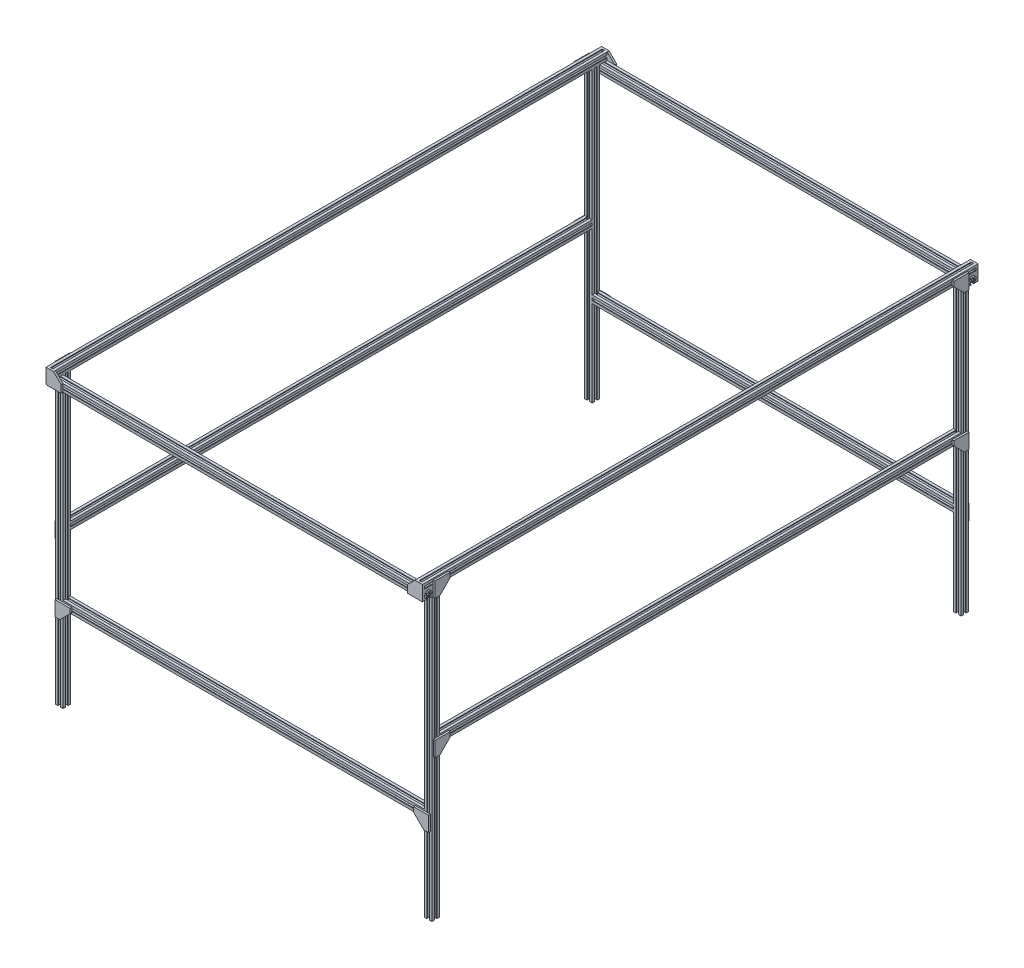
from build123d import *

# Parameters (mm, degrees)
SKETCH1_R                        = 2.5
VERTICAL_LEG_DEPTH               = 767.075
SKETCH2_R                        = 2.5
SHORT_HORIZONTAL_DEPTH           = 479.425
SKETCH3_R                        = 2.5
LONG_HORIZONTAL_DEPTH            = 692.15
SKETCH3_3_R                      = 2.5
LONG_HORIZONTAL_BACKWARDS_DEPTH  = 40
SKETCH2_3_R                      = 2.5
SHORT_HORIZONTAL_BACKWARDS_DEPTH = 20
BRACKETS_1_2_DEPTH               = 5
BRACKET_3_DEPTH                  = 5
BRACKET_4_DEPTH                  = 5


with BuildPart() as part:
    # Sketch1 → Vertical Leg (new body)
    with BuildSketch(Plane(origin=(0, 0, 0), x_dir=(1, 0, 0), z_dir=(0, 1, 0))):
        Polygon((-20, 6.8), (-20, 0), (-13.2, 0), (-13.2, 1.8), (-15.45, 1.8), (-15.45, 3.6), (-12.95, 6.1), (-7.05, 6.1), (-4.55, 3.6), (-4.55, 1.8), (-6.8, 1.8), (-6.8, 0), (0, 0), (0, 6.8), (-1.8, 6.8), (-1.8, 4.55), (-3.6, 4.55), (-6.1, 7.05), (-6.1, 12.95), (-3.6, 15.45), (-1.8, 15.45), (-1.8, 13.2), (0, 13.2), (0, 20), (-6.8, 20), (-6.8, 18.2), (-4.55, 18.2), (-4.55, 16.4), (-7.05, 13.9), (-12.95, 13.9), (-15.45, 16.4), (-15.45, 18.2), (-13.2, 18.2), (-13.2, 20), (-20, 20), (-20, 13.2), (-18.2, 13.2), (-18.2, 15.45), (-16.4, 15.45), (-13.9, 12.95), (-13.9, 7.05), (-16.4, 4.55), (-18.2, 4.55), (-18.2, 6.8), align=None)
        with Locations((-10, 10)):
            Circle(SKETCH1_R, mode=Mode.SUBTRACT)
    extrude(amount=VERTICAL_LEG_DEPTH)

    # Sketch2 → Short Horizontal (add)
    # profile 1 of 2: a face of its own
    with BuildSketch(Plane.ZY.offset(20)):
        Polygon((-20, 235.4), (-20, 228.6), (-13.2, 228.6), (-13.2, 230.4), (-15.45, 230.4), (-15.45, 232.2), (-12.95, 234.7), (-7.05, 234.7), (-4.55, 232.2), (-4.55, 230.4), (-6.8, 230.4), (-6.8, 228.6), (0, 228.6), (0, 235.4), (-1.8, 235.4), (-1.8, 233.15), (-3.6, 233.15), (-6.1, 235.65), (-6.1, 241.55), (-3.6, 244.05), (-1.8, 244.05), (-1.8, 241.8), (0, 241.8), (0, 248.6), (-6.8, 248.6), (-6.8, 246.8), (-4.55, 246.8), (-4.55, 245), (-7.05, 242.5), (-12.95, 242.5), (-15.45, 245), (-15.45, 246.8), (-13.2, 246.8), (-13.2, 248.6), (-20, 248.6), (-20, 241.8), (-18.2, 241.8), (-18.2, 244.05), (-16.4, 244.05), (-13.9, 241.55), (-13.9, 235.65), (-16.4, 233.15), (-18.2, 233.15), (-18.2, 235.4), align=None)
        with Locations((-10, 238.6)):
            Circle(SKETCH2_R, mode=Mode.SUBTRACT)
    # profile 2 of 2: a face of its own
    with BuildSketch(Plane.ZY.offset(20)):
        Polygon((0, 753.875), (0, 747.075), (6.8, 747.075), (6.8, 748.875), (4.55, 748.875), (4.55, 750.675), (7.05, 753.175), (12.95, 753.175), (15.45, 750.675), (15.45, 748.875), (13.2, 748.875), (13.2, 747.075), (20, 747.075), (20, 753.875), (18.2, 753.875), (18.2, 751.625), (16.4, 751.625), (13.9, 754.125), (13.9, 760.025), (16.4, 762.525), (18.2, 762.525), (18.2, 760.275), (20, 760.275), (20, 767.075), (13.2, 767.075), (13.2, 765.275), (15.45, 765.275), (15.45, 763.475), (12.95, 760.975), (7.05, 760.975), (4.55, 763.475), (4.55, 765.275), (6.8, 765.275), (6.8, 767.075), (0, 767.075), (0, 760.275), (1.8, 760.275), (1.8, 762.525), (3.6, 762.525), (6.1, 760.025), (6.1, 754.125), (3.6, 751.625), (1.8, 751.625), (1.8, 753.875), align=None)
        with Locations((10, 757.075)):
            Circle(SKETCH2_R, mode=Mode.SUBTRACT)
    extrude(amount=SHORT_HORIZONTAL_DEPTH)


with BuildPart() as short_horizontal_piece_1:
    # of the separate pieces the step leaves, piece 1, a body of its own (short_horizontal_pieces)
    add(part.part.solids().sort_by_distance((-20, 0, -6.8))[0])

    # Sketch3 → Long Horizontal (add)
    # profile 1 of 2: a face of its own
    with BuildSketch(Plane(origin=(0, 0, -20), x_dir=(-1, 0, 0), z_dir=(0, 0, -1))):
        Polygon((0, 407.8), (0, 401), (6.8, 401), (6.8, 402.8), (4.55, 402.8), (4.55, 404.6), (7.05, 407.1), (12.95, 407.1), (15.45, 404.6), (15.45, 402.8), (13.2, 402.8), (13.2, 401), (20, 401), (20, 407.8), (18.2, 407.8), (18.2, 405.55), (16.4, 405.55), (13.9, 408.05), (13.9, 413.95), (16.4, 416.45), (18.2, 416.45), (18.2, 414.2), (20, 414.2), (20, 421), (13.2, 421), (13.2, 419.2), (15.45, 419.2), (15.45, 417.4), (12.95, 414.9), (7.05, 414.9), (4.55, 417.4), (4.55, 419.2), (6.8, 419.2), (6.8, 421), (0, 421), (0, 414.2), (1.8, 414.2), (1.8, 416.45), (3.6, 416.45), (6.1, 413.95), (6.1, 408.05), (3.6, 405.55), (1.8, 405.55), (1.8, 407.8), align=None)
        with Locations((10, 411)):
            Circle(SKETCH3_R, mode=Mode.SUBTRACT)
    # profile 2 of 2: a face of its own
    with BuildSketch(Plane(origin=(0, 0, -20), x_dir=(-1, 0, 0), z_dir=(0, 0, -1))):
        Polygon((13.2, 768.875), (13.2, 767.075), (20, 767.075), (20, 773.875), (18.2, 773.875), (18.2, 771.625), (16.4, 771.625), (13.9, 774.125), (13.9, 780.025), (16.4, 782.525), (18.2, 782.525), (18.2, 780.275), (20, 780.275), (20, 787.075), (13.2, 787.075), (13.2, 785.275), (15.45, 785.275), (15.45, 783.475), (12.95, 780.975), (7.05, 780.975), (4.55, 783.475), (4.55, 785.275), (6.8, 785.275), (6.8, 787.075), (0, 787.075), (0, 780.275), (1.8, 780.275), (1.8, 782.525), (3.6, 782.525), (6.1, 780.025), (6.1, 774.125), (3.6, 771.625), (1.8, 771.625), (1.8, 773.875), (0, 773.875), (0, 767.075), (6.8, 767.075), (6.8, 768.875), (4.55, 768.875), (4.55, 770.675), (7.05, 773.175), (12.95, 773.175), (15.45, 770.675), (15.45, 768.875), align=None)
        with Locations((10, 777.075)):
            Circle(SKETCH3_R, mode=Mode.SUBTRACT)
    extrude(amount=LONG_HORIZONTAL_DEPTH)


with BuildPart() as short_horizontal_piece_2:
    # of the separate pieces the step leaves, piece 2, a body of its own (short_horizontal_pieces)
    add(part.part.solids().sort_by_distance((-499.425, 753.875, 0))[0])



with BuildPart() as long_horizontal_piece_1:
    # of the separate pieces the step leaves, piece 1, a body of its own (long_horizontal_pieces)
    add(short_horizontal_piece_1.part.solids().sort_by_distance((-20, 0, -6.8))[0])


with BuildPart() as long_horizontal_piece_2:
    # of the separate pieces the step leaves, piece 2, a body of its own (long_horizontal_pieces)
    add(short_horizontal_piece_1.part.solids().sort_by_distance((0, 767.075, -712.15))[0])


    add(long_horizontal_piece_1.part)  # Long Horizontal Backwards merges Long Horizontal piece 1
    # Sketch3_3 → Long Horizontal Backwards (add)
    with BuildSketch(Plane(origin=(0, 0, -20), x_dir=(-1, 0, 0), z_dir=(0, 0, -1))):
        Polygon((0, 773.875), (0, 767.075), (6.8, 767.075), (6.8, 768.875), (4.55, 768.875), (4.55, 770.675), (7.05, 773.175), (12.95, 773.175), (15.45, 770.675), (15.45, 768.875), (13.2, 768.875), (13.2, 767.075), (20, 767.075), (20, 773.875), (18.2, 773.875), (18.2, 771.625), (16.4, 771.625), (13.9, 774.125), (13.9, 780.025), (16.4, 782.525), (18.2, 782.525), (18.2, 780.275), (20, 780.275), (20, 787.075), (13.2, 787.075), (13.2, 785.275), (15.45, 785.275), (15.45, 783.475), (12.95, 780.975), (7.05, 780.975), (4.55, 783.475), (4.55, 785.275), (6.8, 785.275), (6.8, 787.075), (0, 787.075), (0, 780.275), (1.8, 780.275), (1.8, 782.525), (3.6, 782.525), (6.1, 780.025), (6.1, 774.125), (3.6, 771.625), (1.8, 771.625), (1.8, 773.875), align=None)
        with Locations((10, 777.075)):
            Circle(SKETCH3_3_R, mode=Mode.SUBTRACT)
    extrude(amount=-LONG_HORIZONTAL_BACKWARDS_DEPTH)


with BuildPart() as short_horizontal_piece_2_1:
    add(short_horizontal_piece_2.part)

    add(long_horizontal_piece_2.part)  # Short Horizontal Backwards merges Long Horizontal piece 2
    # Sketch2_3 → Short Horizontal Backwards (add)
    with BuildSketch(Plane.ZY.offset(20)):
        Polygon((0, 753.875), (0, 747.075), (6.8, 747.075), (6.8, 748.875), (4.55, 748.875), (4.55, 750.675), (7.05, 753.175), (12.95, 753.175), (15.45, 750.675), (15.45, 748.875), (13.2, 748.875), (13.2, 747.075), (20, 747.075), (20, 753.875), (18.2, 753.875), (18.2, 751.625), (16.4, 751.625), (13.9, 754.125), (13.9, 760.025), (16.4, 762.525), (18.2, 762.525), (18.2, 760.275), (20, 760.275), (20, 767.075), (13.2, 767.075), (13.2, 765.275), (15.45, 765.275), (15.45, 763.475), (12.95, 760.975), (7.05, 760.975), (4.55, 763.475), (4.55, 765.275), (6.8, 765.275), (6.8, 767.075), (0, 767.075), (0, 760.275), (1.8, 760.275), (1.8, 762.525), (3.6, 762.525), (6.1, 760.025), (6.1, 754.125), (3.6, 751.625), (1.8, 751.625), (1.8, 753.875), align=None)
        with Locations((10, 757.075)):
            Circle(SKETCH2_3_R, mode=Mode.SUBTRACT)
    extrude(amount=-SHORT_HORIZONTAL_BACKWARDS_DEPTH)

    # Sketch4 → Brackets 1 _ 2 (add)
    with BuildSketch(Plane(origin=(0, 0, 0), x_dir=(0, 0, -1), z_dir=(1, 0, 0))):
        Polygon((3.509446778, 743.565553222), (16.490553222, 743.565553222), (43.509446778, 770.584446778), (43.509446778, 783.565553222), (3.509446778, 783.565553222), align=None)
        Polygon((3.854478715, 417.145521285), (43.854478715, 417.145521285), (43.854478715, 404.854478715), (16.145521285, 377.145521285), (3.854478715, 377.145521285), align=None)
    extrude(amount=BRACKETS_1_2_DEPTH)

    # Sketch5 → Bracket 3 (add)
    with BuildSketch(Plane.XY.offset(20)):
        Polygon((-40, 747.075), (-40, 767.075), (-20, 787.075), (0, 787.075), (0, 747.075), align=None)
    extrude(amount=BRACKET_3_DEPTH)

    # Sketch6 → Bracket 4 (add)
    with BuildSketch(Plane.XY):
        Polygon((-43.679581294, 244.920418706), (-43.679581294, 232.279581294), (-16.320418706, 204.920418706), (-3.679581294, 204.920418706), (-3.679581294, 244.920418706), align=None)
    extrude(amount=BRACKET_4_DEPTH)

    # Mirror1: Short Horizontal piece 2 across plane


with BuildPart() as short_horizontal_piece_2_2:
    add(short_horizontal_piece_2_1.part)
    add(short_horizontal_piece_2_1.part.mirror(Plane(origin=(0, 0, -712.15), x_dir=(1, 0, 0), z_dir=(0, 0, -1))))

    # Mirror2: Short Horizontal piece 2 across plane


with BuildPart() as short_horizontal_piece_2_3:
    add(short_horizontal_piece_2_2.part)
    add(short_horizontal_piece_2_2.part.mirror(Plane.ZY.offset(499.425)))


solid = short_horizontal_piece_2_3.part
